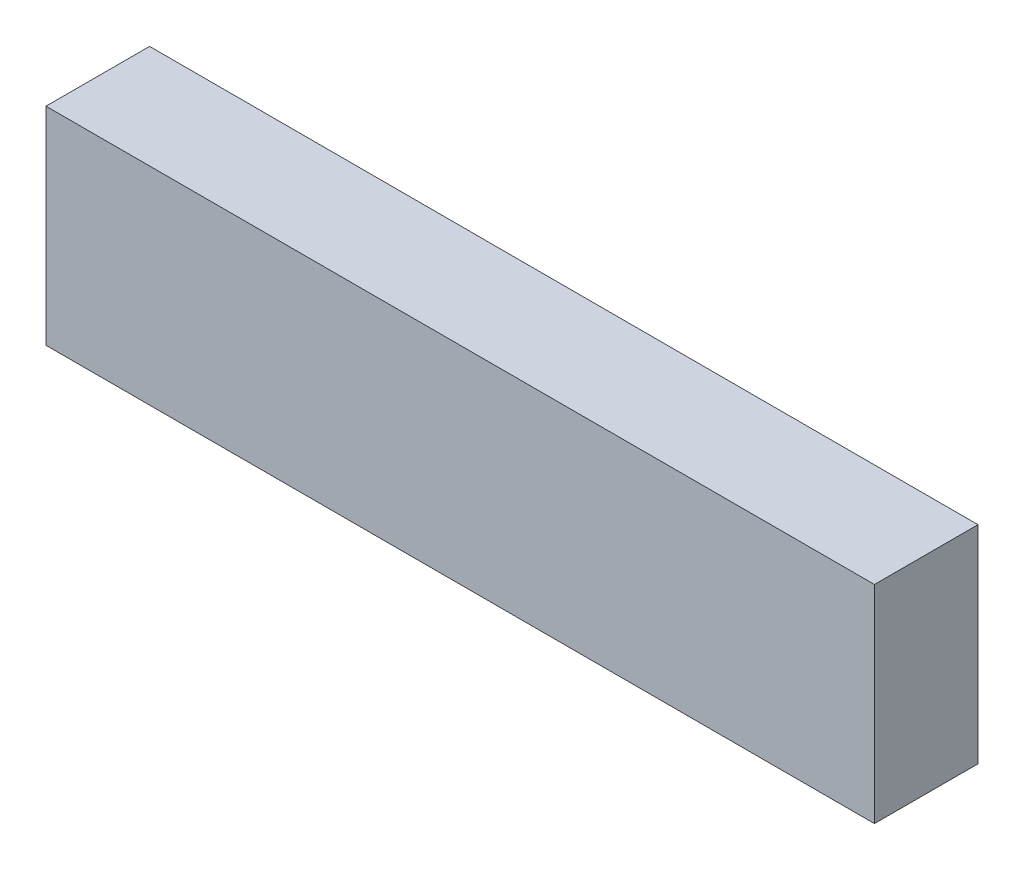
from build123d import *

# Parameters (mm, degrees)
SKETCH1_W           = 508
SKETCH1_H           = 127
BOSS_EXTRUDE1_DEPTH = 63.5


with BuildPart() as part:
    # Sketch1 → Boss-Extrude1 (new body)
    with BuildSketch(Plane.XY):
        with Locations((254, 63.5)):
            Rectangle(SKETCH1_W, SKETCH1_H)
    extrude(amount=BOSS_EXTRUDE1_DEPTH)


solid = part.part
